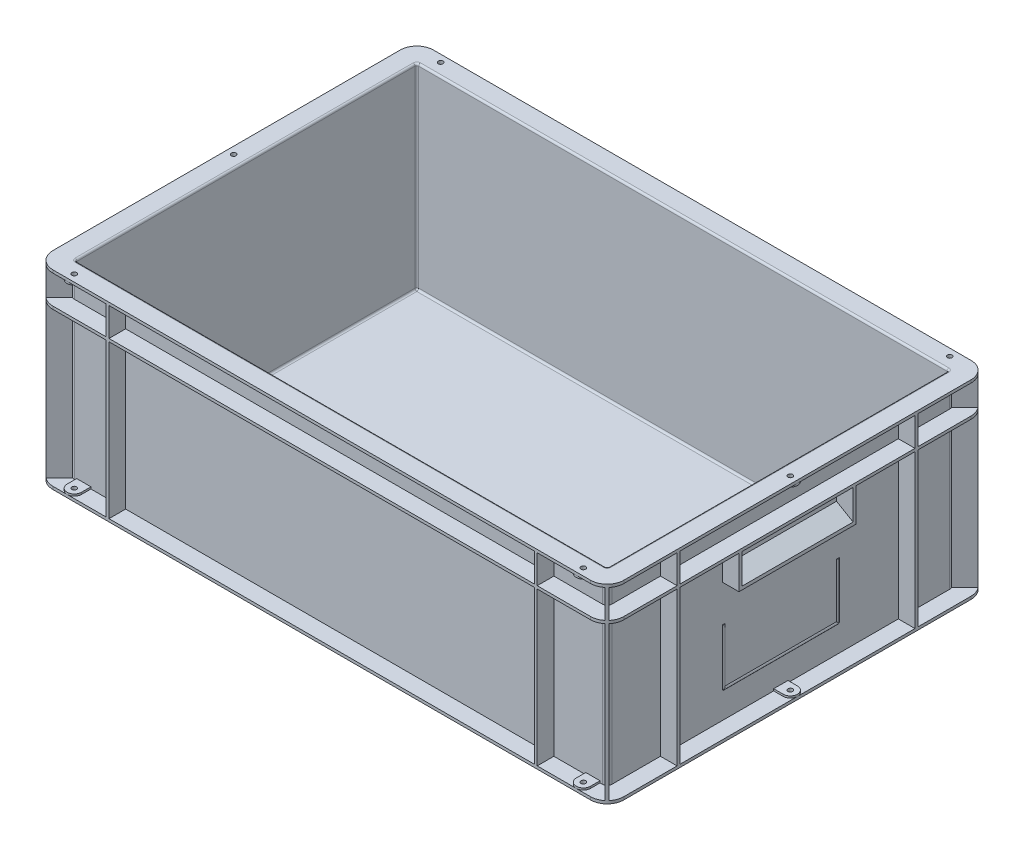
from build123d import *

# Parameters (mm, degrees)
EXTRUSION2_DEPTH            = 200
EXTRUSION2_DEPTH_BACK       = 9
COQUE1_T                    = -3
EXTRUSION3_START            = 197
EXTRUSION3_DEPTH            = 3
EXTRUSION4_DEPTH            = 3
EXTRUSION7_START            = 164
EXTRUSION7_DEPTH            = 3
ESQUISSE6_W                 = 17.5
ESQUISSE6_H                 = 3
ESQUISSE6_W_2               = 3
ESQUISSE6_H_2               = 17.5
EXTRUSION5_DEPTH            = 197
SYM_TRIE2_COPY_1_SKETCH_W   = 17.5
SYM_TRIE2_COPY_1_SKETCH_H   = 3
SYM_TRIE2_COPY_1_SKETCH_W_2 = 3
SYM_TRIE2_COPY_1_SKETCH_H_2 = 17.5
SYM_TRIE2_COPY_1_DEPTH      = 197
EXTRUSION6_START            = 282.5
ESQUISSE7_W                 = 3
ESQUISSE7_H                 = 35
EXTRUSION6_DEPTH            = 17.5
EXTRUSION13_START           = -282.5
ESQUISSE7_2_W               = 3
ESQUISSE7_2_H               = 35
EXTRUSION13_DEPTH           = 17.5
EXTRUSION8_DEPTH            = 58.5
EXTRUSION9_DEPTH            = 5
EXTRUSION10_START           = 195
EXTRUSION10_DEPTH           = 2
ESQUISSE10_R                = 2.5
EXTRUSION11_DEPTH           = 5
EXTRUSION12_START           = 195
ESQUISSE10_2_R              = 2.5
EXTRUSION12_DEPTH           = 6
EXTRUSION14_DEPTH           = 60
EXTRUSION14_DEPTH_BACK      = 60
EXTRUSION15_START           = 31.5
EXTRUSION15_DEPTH           = 58.5
R_VOLUTION1_ANGLE           = 90
CONG_1_R                    = 2


with BuildPart() as part:
    # Esquisse4 → Extrusion2 (new body, two sides)
    with BuildSketch(Plane(origin=(0, 0, 0), x_dir=(1, 0, 0), z_dir=(0, 1, 0))) as extrusion2_sk:
        with BuildLine():
            Line((-277.5, 182.5), (277.5, 182.5))
            ThreePointArc((277.5, 182.5), (281.035533906, 181.035533906), (282.5, 177.5))
            Line((282.5, 177.5), (282.5, -177.5))
            ThreePointArc((282.5, -177.5), (281.035533906, -181.035533906), (277.5, -182.5))
            Line((277.5, -182.5), (-277.5, -182.5))
            ThreePointArc((-277.5, -182.5), (-281.035533906, -181.035533906), (-282.5, -177.5))
            Line((-282.5, -177.5), (-282.5, 177.5))
            ThreePointArc((-282.5, 177.5), (-281.035533906, 181.035533906), (-277.5, 182.5))
        make_face()
    extrude(amount=EXTRUSION2_DEPTH)
    extrude(extrusion2_sk.sketch, amount=-EXTRUSION2_DEPTH_BACK)

    # Coque1
    coque1_openings = [part.faces().sort_by_distance(p)[0] for p in [
        (0, 200, 0),
    ]]
    offset(amount=COQUE1_T, openings=coque1_openings, kind=Kind.INTERSECTION)

    # Esquisse5 → Extrusion3 (add)
    with BuildSketch(Plane(origin=(0, 0, 0), x_dir=(1, 0, 0), z_dir=(0, 1, 0)).offset(EXTRUSION3_START)):
        with BuildLine():
            Line((-300, 182.5), (-300, -182.5))
            ThreePointArc((-300, -182.5), (-294.874368671, -194.874368671), (-282.5, -200))
            Line((-282.5, -200), (282.5, -200))
            ThreePointArc((282.5, -200), (294.874368671, -194.874368671), (300, -182.5))
            Line((300, -182.5), (300, 182.5))
            ThreePointArc((300, 182.5), (294.874368671, 194.874368671), (282.5, 200))
            Line((282.5, 200), (-282.5, 200))
            ThreePointArc((-282.5, 200), (-294.874368671, 194.874368671), (-300, 182.5))
        make_face()
        with BuildLine():
            Line((279.5, -177.5), (279.5, 177.5))
            ThreePointArc((279.5, 177.5), (278.914213562, 178.914213562), (277.5, 179.5))
            Line((277.5, 179.5), (-277.5, 179.5))
            ThreePointArc((-277.5, 179.5), (-278.914213562, 178.914213562), (-279.5, 177.5))
            Line((-279.5, 177.5), (-279.5, -177.5))
            ThreePointArc((-279.5, -177.5), (-278.914213562, -178.914213562), (-277.5, -179.5))
            Line((-277.5, -179.5), (277.5, -179.5))
            ThreePointArc((277.5, -179.5), (278.914213562, -178.914213562), (279.5, -177.5))
        make_face(mode=Mode.SUBTRACT)
    extrude(amount=EXTRUSION3_DEPTH)

    # Esquisse5_2 → Extrusion4 (add)
    with BuildSketch(Plane(origin=(0, 0, 0), x_dir=(1, 0, 0), z_dir=(0, 1, 0))):
        with BuildLine():
            Line((-300, 182.5), (-300, -182.5))
            ThreePointArc((-300, -182.5), (-294.874368671, -194.874368671), (-282.5, -200))
            Line((-282.5, -200), (282.5, -200))
            ThreePointArc((282.5, -200), (294.874368671, -194.874368671), (300, -182.5))
            Line((300, -182.5), (300, 182.5))
            ThreePointArc((300, 182.5), (294.874368671, 194.874368671), (282.5, 200))
            Line((282.5, 200), (-282.5, 200))
            ThreePointArc((-282.5, 200), (-294.874368671, 194.874368671), (-300, 182.5))
        make_face()
        with BuildLine():
            Line((279.5, -177.5), (279.5, 177.5))
            ThreePointArc((279.5, 177.5), (278.914213562, 178.914213562), (277.5, 179.5))
            Line((277.5, 179.5), (-277.5, 179.5))
            ThreePointArc((-277.5, 179.5), (-278.914213562, 178.914213562), (-279.5, 177.5))
            Line((-279.5, 177.5), (-279.5, -177.5))
            ThreePointArc((-279.5, -177.5), (-278.914213562, -178.914213562), (-277.5, -179.5))
            Line((-277.5, -179.5), (277.5, -179.5))
            ThreePointArc((277.5, -179.5), (278.914213562, -178.914213562), (279.5, -177.5))
        make_face(mode=Mode.SUBTRACT)
    extrude(amount=EXTRUSION4_DEPTH)

    # Esquisse5_4 → Extrusion7 (add)
    with BuildSketch(Plane(origin=(0, 0, 0), x_dir=(1, 0, 0), z_dir=(0, 1, 0)).offset(EXTRUSION7_START)):
        with BuildLine():
            Line((-300, 182.5), (-300, -182.5))
            ThreePointArc((-300, -182.5), (-294.874368671, -194.874368671), (-282.5, -200))
            Line((-282.5, -200), (282.5, -200))
            ThreePointArc((282.5, -200), (294.874368671, -194.874368671), (300, -182.5))
            Line((300, -182.5), (300, 182.5))
            ThreePointArc((300, 182.5), (294.874368671, 194.874368671), (282.5, 200))
            Line((282.5, 200), (-282.5, 200))
            ThreePointArc((-282.5, 200), (-294.874368671, 194.874368671), (-300, 182.5))
        make_face()
        with BuildLine():
            Line((279.5, -177.5), (279.5, 177.5))
            ThreePointArc((279.5, 177.5), (278.914213562, 178.914213562), (277.5, 179.5))
            Line((277.5, 179.5), (-277.5, 179.5))
            ThreePointArc((-277.5, 179.5), (-278.914213562, 178.914213562), (-279.5, 177.5))
            Line((-279.5, 177.5), (-279.5, -177.5))
            ThreePointArc((-279.5, -177.5), (-278.914213562, -178.914213562), (-277.5, -179.5))
            Line((-277.5, -179.5), (277.5, -179.5))
            ThreePointArc((277.5, -179.5), (278.914213562, -178.914213562), (279.5, -177.5))
        make_face(mode=Mode.SUBTRACT)
    extrude(amount=EXTRUSION7_DEPTH)

    # Esquisse6 → Extrusion5 (add)
    with BuildSketch(Plane(origin=(0, 0, 0), x_dir=(1, 0, 0), z_dir=(0, 1, 0))):
        with Locations((-291.25, 125)):
            Rectangle(ESQUISSE6_W, ESQUISSE6_H)
        with Locations((-225, 191.25)):
            Rectangle(ESQUISSE6_W_2, ESQUISSE6_H_2)
        with BuildLine():
            Line((-295.889488178, 193.768167834), (-281.933344563, 179.812024219))
            ThreePointArc((-281.933344563, 179.812024219), (-281.035533906, 181.035533906), (-279.812024219, 181.933344563))
            Line((-279.812024219, 181.933344563), (-293.768167834, 195.889488178))
            ThreePointArc((-293.768167834, 195.889488178), (-294.874368671, 194.874368671), (-295.889488178, 193.768167834))
        make_face()
    extrusion5 = extrude(amount=EXTRUSION5_DEPTH)

    # Sym_trie1: Extrusion5 across plane
    add(extrusion5.mirror(Plane(origin=(0, 0, 0), x_dir=(0, 0, 1), z_dir=(1, 0, 0))))

    # Sym_trie2: Extrusion5 across plane
    add(extrusion5.mirror(Plane.XY))

    # Sym_trie2 copy 1 sketch → Sym_trie2 copy 1 (add)
    with BuildSketch(Plane(origin=(0, 0, 0), x_dir=(-1, 0, 0), z_dir=(0, 1, 0))):
        with Locations((-291.25, 125)):
            Rectangle(SYM_TRIE2_COPY_1_SKETCH_W, SYM_TRIE2_COPY_1_SKETCH_H)
        with Locations((-225, 191.25)):
            Rectangle(SYM_TRIE2_COPY_1_SKETCH_W_2, SYM_TRIE2_COPY_1_SKETCH_H_2)
        with BuildLine():
            Line((-295.889488178, 193.768167834), (-281.933344563, 179.812024219))
            ThreePointArc((-281.933344563, 179.812024219), (-281.035533906, 181.035533906), (-279.812024219, 181.933344563))
            Line((-279.812024219, 181.933344563), (-293.768167834, 195.889488178))
            ThreePointArc((-293.768167834, 195.889488178), (-294.874368671, 194.874368671), (-295.889488178, 193.768167834))
        make_face()
    extrude(amount=SYM_TRIE2_COPY_1_DEPTH)

    # Esquisse7 → Extrusion6 (add)
    with BuildSketch(Plane(origin=(0, 0, 0), x_dir=(0, 0, -1), z_dir=(1, 0, 0)).offset(EXTRUSION6_START)):
        with Locations((-60, 146.5)):
            Rectangle(ESQUISSE7_W, ESQUISSE7_H)
        with Locations((60, 146.5)):
            Rectangle(ESQUISSE7_W, ESQUISSE7_H)
    extrude(amount=EXTRUSION6_DEPTH)

    # Esquisse7_2 → Extrusion13 (add)
    with BuildSketch(Plane(origin=(0, 0, 0), x_dir=(0, 0, -1), z_dir=(1, 0, 0)).offset(EXTRUSION13_START)):
        with Locations((-60, 146.5)):
            Rectangle(ESQUISSE7_2_W, ESQUISSE7_2_H)
        with Locations((60, 146.5)):
            Rectangle(ESQUISSE7_2_W, ESQUISSE7_2_H)
    extrude(amount=-EXTRUSION13_DEPTH)

    # Esquisse8 → Extrusion8 (add, symmetric)
    with BuildSketch(Plane.XY):
        Polygon((282.5, 142.567731326), (282.5, 139.103629711), (300, 129), (300, 132.464101615), align=None)
    extrusion8 = extrude(amount=EXTRUSION8_DEPTH, both=True)

    # Sym_trie6: Extrusion8 across plane
    add(extrusion8.mirror(Plane(origin=(0, 0, 0), x_dir=(0, 0, 1), z_dir=(1, 0, 0))))

    # Esquisse9 → Extrusion9 (add)
    with BuildSketch(Plane(origin=(0, 0, 0), x_dir=(1, 0, 0), z_dir=(0, 1, 0))):
        with BuildLine():
            Line((282.5, 7.5), (282.5, -7.5))
            Line((282.5, -7.5), (292.5, -7.5))
            ThreePointArc((292.5, -7.5), (300, 0), (292.5, 7.5))
            Line((292.5, 7.5), (282.5, 7.5))
        make_face()
        with BuildLine():
            Line((-275, 182.5), (-260, 182.5))
            Line((-260, 182.5), (-260, 192.5))
            ThreePointArc((-260, 192.5), (-267.5, 200), (-275, 192.5))
            Line((-275, 192.5), (-275, 182.5))
        make_face()
        with BuildLine():
            Line((-282.5, 7.5), (-282.5, -7.5))
            Line((-282.5, -7.5), (-292.5, -7.5))
            ThreePointArc((-292.5, -7.5), (-300, 0), (-292.5, 7.5))
            Line((-292.5, 7.5), (-282.5, 7.5))
        make_face()
        with BuildLine():
            Line((-275, -182.5), (-260, -182.5))
            Line((-260, -182.5), (-260, -192.5))
            ThreePointArc((-260, -192.5), (-267.5, -200), (-275, -192.5))
            Line((-275, -192.5), (-275, -182.5))
        make_face()
        with BuildLine():
            Line((275, 192.5), (275, 182.5))
            Line((275, 182.5), (260, 182.5))
            Line((260, 182.5), (260, 192.5))
            ThreePointArc((260, 192.5), (267.5, 200), (275, 192.5))
        make_face()
        with BuildLine():
            Line((275, -192.5), (275, -182.5))
            Line((275, -182.5), (260, -182.5))
            Line((260, -182.5), (260, -192.5))
            ThreePointArc((260, -192.5), (267.5, -200), (275, -192.5))
        make_face()
    extrude(amount=EXTRUSION9_DEPTH)

    # Esquisse9_2 → Extrusion10 (add)
    with BuildSketch(Plane(origin=(0, 0, 0), x_dir=(1, 0, 0), z_dir=(0, 1, 0)).offset(EXTRUSION10_START)):
        with BuildLine():
            Line((282.5, 7.5), (282.5, -7.5))
            Line((282.5, -7.5), (292.5, -7.5))
            ThreePointArc((292.5, -7.5), (300, 0), (292.5, 7.5))
            Line((292.5, 7.5), (282.5, 7.5))
        make_face()
        with BuildLine():
            Line((-275, 182.5), (-260, 182.5))
            Line((-260, 182.5), (-260, 192.5))
            ThreePointArc((-260, 192.5), (-267.5, 200), (-275, 192.5))
            Line((-275, 192.5), (-275, 182.5))
        make_face()
        with BuildLine():
            Line((-282.5, 7.5), (-282.5, -7.5))
            Line((-282.5, -7.5), (-292.5, -7.5))
            ThreePointArc((-292.5, -7.5), (-300, 0), (-292.5, 7.5))
            Line((-292.5, 7.5), (-282.5, 7.5))
        make_face()
        with BuildLine():
            Line((-275, -182.5), (-260, -182.5))
            Line((-260, -182.5), (-260, -192.5))
            ThreePointArc((-260, -192.5), (-267.5, -200), (-275, -192.5))
            Line((-275, -192.5), (-275, -182.5))
        make_face()
        with BuildLine():
            Line((275, 192.5), (275, 182.5))
            Line((275, 182.5), (260, 182.5))
            Line((260, 182.5), (260, 192.5))
            ThreePointArc((260, 192.5), (267.5, 200), (275, 192.5))
        make_face()
        with BuildLine():
            Line((275, -192.5), (275, -182.5))
            Line((275, -182.5), (260, -182.5))
            Line((260, -182.5), (260, -192.5))
            ThreePointArc((260, -192.5), (267.5, -200), (275, -192.5))
        make_face()
    extrude(amount=EXTRUSION10_DEPTH)

    # Esquisse10 → Extrusion11 (cut)
    with BuildSketch(Plane(origin=(0, 0, 0), x_dir=(1, 0, 0), z_dir=(0, 1, 0))):
        with Locations((267.5, -192.5)):
            Circle(ESQUISSE10_R)
        with Locations((292.5, 0)):
            Circle(ESQUISSE10_R)
        with Locations((267.5, 192.5)):
            Circle(ESQUISSE10_R)
        with Locations((-267.5, 192.5)):
            Circle(ESQUISSE10_R)
        with Locations((-292.5, 0)):
            Circle(ESQUISSE10_R)
        with Locations((-267.5, -192.5)):
            Circle(ESQUISSE10_R)
    extrude(amount=EXTRUSION11_DEPTH, mode=Mode.SUBTRACT)

    # Esquisse10_2 → Extrusion12 (cut, through all)
    with BuildSketch(Plane(origin=(0, 0, 0), x_dir=(1, 0, 0), z_dir=(0, 1, 0)).offset(EXTRUSION12_START)):
        with Locations((267.5, -192.5)):
            Circle(ESQUISSE10_2_R)
        with Locations((292.5, 0)):
            Circle(ESQUISSE10_2_R)
        with Locations((267.5, 192.5)):
            Circle(ESQUISSE10_2_R)
        with Locations((-267.5, 192.5)):
            Circle(ESQUISSE10_2_R)
        with Locations((-292.5, 0)):
            Circle(ESQUISSE10_2_R)
        with Locations((-267.5, -192.5)):
            Circle(ESQUISSE10_2_R)
    extrude(amount=EXTRUSION12_DEPTH, mode=Mode.SUBTRACT)

    # Esquisse11 → Extrusion14 (add, two sides)
    with BuildSketch(Plane.XY) as extrusion14_sk:
        with BuildLine():
            Line((282.5, 33), (282.5, 30))
            ThreePointArc((282.5, 30), (283.25, 31.5), (282.5, 33))
        make_face()
    extrude(amount=EXTRUSION14_DEPTH)
    extrude(extrusion14_sk.sketch, amount=-EXTRUSION14_DEPTH_BACK)

    # Esquisse12 → Extrusion15 (add)
    with BuildSketch(Plane(origin=(0, 0, 0), x_dir=(1, 0, 0), z_dir=(0, 1, 0)).offset(EXTRUSION15_START)):
        with BuildLine():
            Line((282.5, -61.5), (282.5, -58.5))
            ThreePointArc((282.5, -58.5), (283.25, -60), (282.5, -61.5))
        make_face()
    extrusion15 = extrude(amount=EXTRUSION15_DEPTH)

    # Esquisse13 → R_volution1 (revolve)
    with BuildSketch(Plane.XY.offset(60)):
        with BuildLine():
            Line((283.25, 31.5), (282.5, 31.5))
            Line((282.5, 31.5), (282.5, 30))
            ThreePointArc((282.5, 30), (283.052050983, 30.661474508), (283.25, 31.5))
        make_face()
    r_volution1 = revolve(axis=Axis((181.975118895, 31.5, 60), (-1, 0, 0)), revolution_arc=R_VOLUTION1_ANGLE)

    # Sym_trie7: Extrusion15, R_volution1 across plane
    add(extrusion15.mirror(Plane.XY))
    add(r_volution1.mirror(Plane.XY))

    # Cong_1
    cong_1_edges = [part.edges().sort_by_distance(p)[0] for p in [
        (-281.035533906, -9, 181.035533906),
        (-281.035533906, 0, -181.035533906),
        (0, -9, 182.5),
        (-281.035533906, 0, 181.035533906),
        (-282.5, 0, 0),
        (0, 0, -182.5),
        (281.035533906, 0, -181.035533906),
        (282.5, 0, 0),
        (281.035533906, 0, 181.035533906),
        (0, 0, 182.5),
        (281.035533906, -9, 181.035533906),
        (282.5, -9, 0),
        (281.035533906, -9, -181.035533906),
        (0, -9, -182.5),
        (-281.035533906, -9, -181.035533906),
        (-278.914213562, -6, -178.914213562),
        (0, -6, -179.5),
        (278.914213562, -6, -178.914213562),
        (279.5, -6, 0),
        (278.914213562, -6, 178.914213562),
        (0, -6, 179.5),
        (-278.914213562, -6, 178.914213562),
        (-279.5, -6, 0),
        (-278.914213562, 200, -178.914213562),
        (-279.5, 200, 0),
        (-278.914213562, 200, 178.914213562),
        (0, 200, 179.5),
        (278.914213562, 200, 178.914213562),
        (279.5, 200, 0),
        (278.914213562, 200, -178.914213562),
        (0, 200, -179.5),
        (-282.5, -9, 0),
    ]]
    fillet(cong_1_edges, radius=CONG_1_R)


solid = part.part
